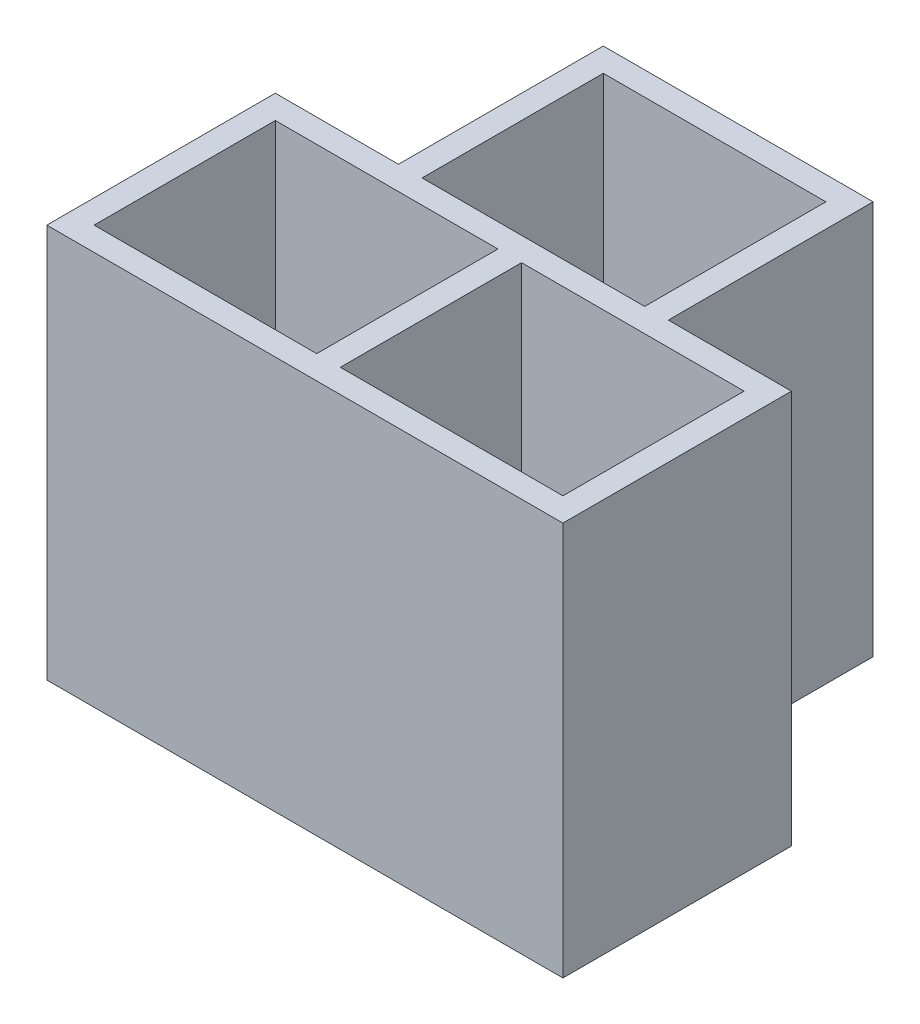
from build123d import *

# Parameters (mm, degrees)
SKETCH1_W               = 13.1
SKETCH1_H               = 5.8
BOSS_EXTRUDE1_DEPTH     = 5
SKETCH10_W              = 5.65
SKETCH10_H              = 4.6
CUT_EXTRUDE7_DEPTH      = 6.6
SKETCH9_R               = 0.75
CUT_EXTRUDE6_DEPTH      = 6
CUT_EXTRUDE6_DEPTH_BACK = 6
BOSS_EXTRUDE2_START     = -5
BOSS_EXTRUDE2_DEPTH     = 10
SKETCH12_W              = 5.65
SKETCH12_H              = 4.6
SKETCH12_R              = 0.75
BOSS_EXTRUDE3_DEPTH     = 3.4


with BuildPart() as part:
    # Sketch1 → Boss-Extrude1 (new body, symmetric)
    with BuildSketch(Plane(origin=(0, 0, 0), x_dir=(1, 0, 0), z_dir=(0, 1, 0))):
        Rectangle(SKETCH1_W, SKETCH1_H)
    extrude(amount=BOSS_EXTRUDE1_DEPTH, both=True)

    # Sketch10 → Cut-Extrude7 (cut)
    with BuildSketch(Plane(origin=(0, 5, 0), x_dir=(1, 0, 0), z_dir=(0, 1, 0))):
        with Locations((-3.125, 0)):
            Rectangle(SKETCH10_W, SKETCH10_H)
        with Locations((3.125, 0)):
            Rectangle(SKETCH10_W, SKETCH10_H)
    extrude(amount=-CUT_EXTRUDE7_DEPTH, mode=Mode.SUBTRACT)

    # Sketch9 → Cut-Extrude6 (cut, two sides)
    with BuildSketch(Plane(origin=(0, 0, 0), x_dir=(1, 0, 0), z_dir=(0, 1, 0))) as cut_extrude6_sk:
        with Locations((-4.625, 0)):
            Circle(SKETCH9_R)
        with Locations((-1.625, 0)):
            Circle(SKETCH9_R)
        with Locations((1.625, 0)):
            Circle(SKETCH9_R)
        with Locations((4.625, 0)):
            Circle(SKETCH9_R)
    extrude(amount=CUT_EXTRUDE6_DEPTH, mode=Mode.SUBTRACT)
    extrude(cut_extrude6_sk.sketch, amount=-CUT_EXTRUDE6_DEPTH_BACK, mode=Mode.SUBTRACT)

    # Sketch11 → Boss-Extrude2 (add)
    with BuildSketch(Plane(origin=(0, 0, 0), x_dir=(1, 0, 0), z_dir=(0, 1, 0)).offset(BOSS_EXTRUDE2_START)):
        Polygon((-3.425, 8.1), (-3.425, 2.9), (-2.825, 2.9), (-2.825, 7.5), (2.825, 7.5), (2.825, 2.9), (3.425, 2.9), (3.425, 8.1), align=None)
    extrude(amount=BOSS_EXTRUDE2_DEPTH)

    # Sketch12 → Boss-Extrude3 (add)
    with BuildSketch(Plane.XZ.offset(5)):
        with Locations((0, -5.2)):
            Rectangle(SKETCH12_W, SKETCH12_H)
        with Locations((-1.5, -5.2)):
            Circle(SKETCH12_R, mode=Mode.SUBTRACT)
        with Locations((1.5, -5.2)):
            Circle(SKETCH12_R, mode=Mode.SUBTRACT)
    extrude(amount=-BOSS_EXTRUDE3_DEPTH)


solid = part.part
